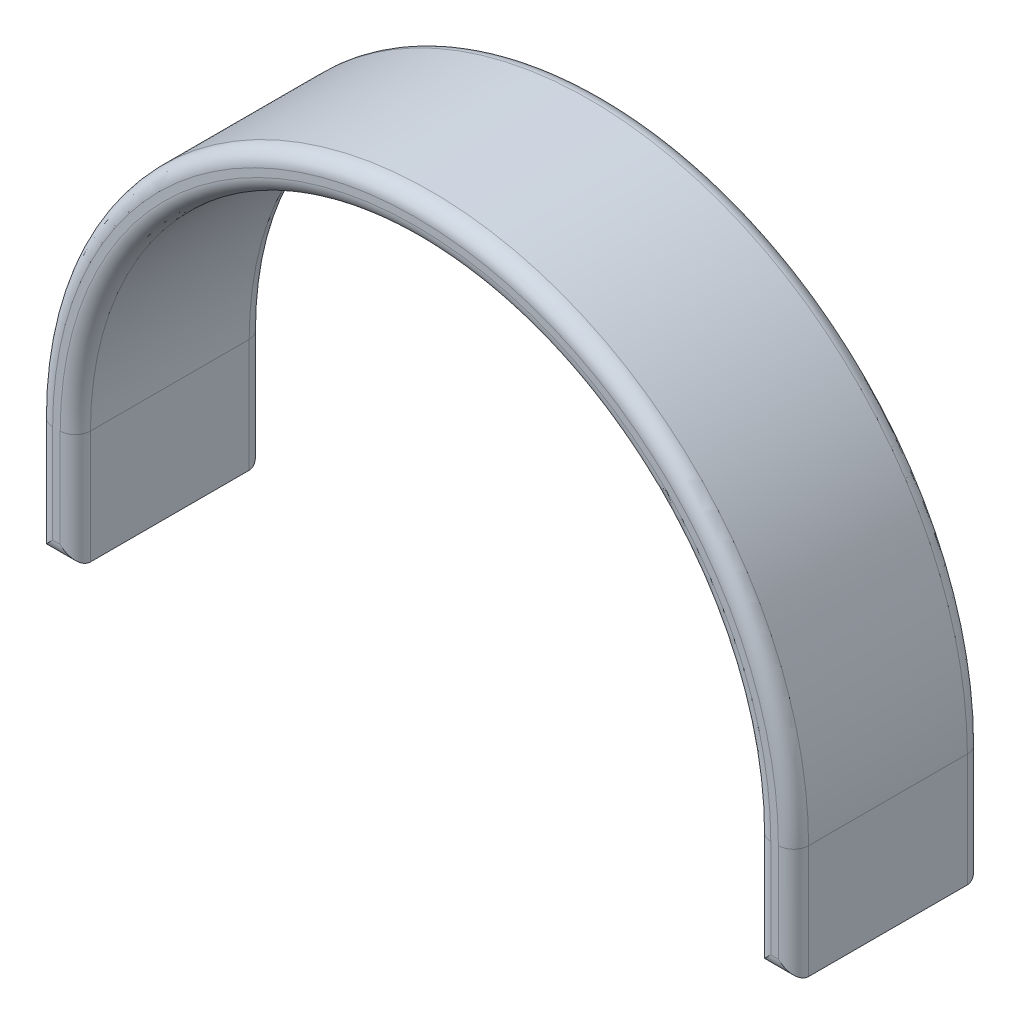
from build123d import *

# Parameters (mm, degrees)
BOSS_EXTRUDE1_DEPTH = 25
FILLET1_R           = 2


with BuildPart() as part:
    # Sketch1 → Boss-Extrude1 (new body)
    with BuildSketch(Plane.XY):
        with BuildLine():
            Line((-50, 0), (-50, -15))
            Line((-50, -15), (-45, -15))
            Line((-45, -15), (-45, 0))
            ThreePointArc((-45, 0), (0, 45), (45, 0))
            Line((45, 0), (45, -15))
            Line((45, -15), (50, -15))
            Line((50, -15), (50, 0))
            ThreePointArc((50, 0), (0, 50), (-50, 0))
        make_face()
    extrude(amount=BOSS_EXTRUDE1_DEPTH)

    # Fillet1
    fillet1_edges = [part.edges().sort_by_distance(p)[0] for p in [
        (-45, -7.5, 0),
        (-47.5, -15, 0),
        (-50, -7.5, 0),
        (0, 50, 0),
        (-47.5, -15, 25),
        (-45, -7.5, 25),
        (0, 45, 25),
        (45, -7.5, 25),
        (47.5, -15, 25),
        (50, -7.5, 25),
        (0, 50, 25),
        (50, -7.5, 0),
        (-50, -7.5, 25),
        (47.5, -15, 0),
        (45, -7.5, 0),
        (0, 45, 0),
    ]]
    fillet(fillet1_edges, radius=FILLET1_R)


solid = part.part
